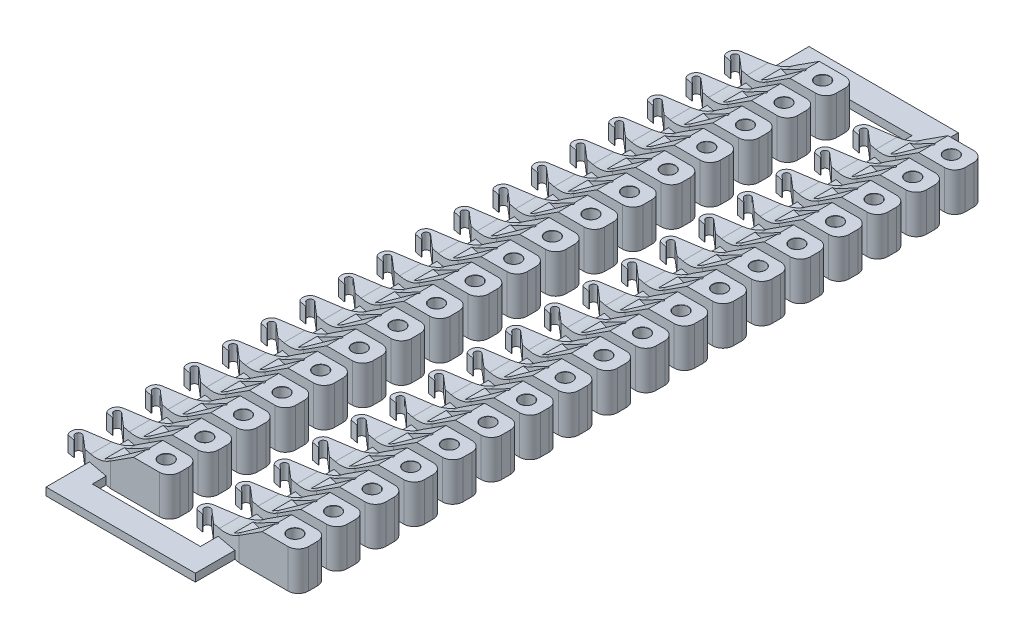
from build123d import *

# Parameters (mm, degrees)
SKETCH1_R                = 0.27
BOSS_EXTRUDE1_DEPTH      = 1.5
CUT_EXTRUDE1_DEPTH       = 1.57
CUT_EXTRUDE1_DEPTH_BACK  = 1.57
FILLET1_R                = 0.01
FILLET2_R                = 1.5
FILLET3_R                = 0.4
CUT_EXTRUDE2_DEPTH       = 0.8
FILLET4_R                = 0.05
LPATTERN2_COUNT          = 18
LPATTERN2_PITCH          = 1.5
SKETCH3_W                = 0.8
SKETCH3_H                = 0.3
BOSS_EXTRUDE2_DEPTH      = 2.0001
BOSS_EXTRUDE2_DEPTH_BACK = 27
LPATTERN4_COUNT          = 2
LPATTERN4_PITCH          = 5
SKETCH5_W                = 5.8
SKETCH5_H                = 0.9301
SKETCH5_H_2              = 0.0699
SKETCH5_H_3              = 0.43
SKETCH5_H_4              = 0.57
BOSS_EXTRUDE3_DEPTH      = 0.3


with BuildPart() as part:
    # Sketch1 → Boss-Extrude1 (new body)
    with BuildSketch(Plane(origin=(0, 0, 0), x_dir=(1, 0, 0), z_dir=(0, 1, 0))):
        with BuildLine():
            Line((0.7, -0.57), (0.7, 0.57))
            Line((0.7, 0.57), (-1.6, 0.57))
            Line((-1.6, 0.57), (-3.448849779, 0.285704322))
            ThreePointArc((-3.448849779, 0.285704322), (-3.676095639, 0.10009665), (-3.623939692, -0.188643104))
            Line((-3.623939692, -0.188643104), (-3.34104042, -0.241947849))
            Line((-3.34104042, -0.241947849), (-3.34104042, -0.220416717))
            Line((-3.34104042, -0.220416717), (-3.486679159, -0.094774919))
            ThreePointArc((-3.486679159, -0.094774919), (-3.499692238, 0.08176184), (-3.323155479, 0.094774919))
            Line((-3.323155479, 0.094774919), (-2.818770339, -0.340355572))
            Line((-2.818770339, -0.340355572), (-1.6, -0.57))
            Line((-1.6, -0.57), (0.7, -0.57))
        make_face()
        Circle(SKETCH1_R, mode=Mode.SUBTRACT)
    extrude(amount=BOSS_EXTRUDE1_DEPTH)

    # Sketch2 → Cut-Extrude1 (cut, two sides)
    with BuildSketch(Plane.XY) as cut_extrude1_sk:
        Polygon((-4.254461252, 0.6), (-2.1, 0.6), (-0.7, 1.5), (-4.254461252, 1.5), align=None)
    extrude(amount=CUT_EXTRUDE1_DEPTH, mode=Mode.SUBTRACT)
    extrude(cut_extrude1_sk.sketch, amount=-CUT_EXTRUDE1_DEPTH_BACK, mode=Mode.SUBTRACT)

    # Fillet1
    fillet1_edges = [part.edges().sort_by_distance(p)[0] for p in [
        (-0.27, 0, 0),
        (-0.27, 1.5, 0),
    ]]
    fillet(fillet1_edges, radius=FILLET1_R)

    # Fillet2
    fillet2_edges = [part.edges().sort_by_distance(p)[0] for p in [
        (-2.1, 0.6, -0.008663527),
    ]]
    fillet(fillet2_edges, radius=FILLET2_R)

    # Fillet3
    fillet3_edges = [part.edges().sort_by_distance(p)[0] for p in [
        (0.7, 0.75, -0.57),
        (0.7, 0.75, 0.57),
    ]]
    fillet(fillet3_edges, radius=FILLET3_R)

    # Sketch4 → Cut-Extrude2 (cut)
    with BuildSketch(Plane(origin=(0, 1.5, 0), x_dir=(1, 0, 0), z_dir=(0, 1, 0))):
        Polygon((-0.5, 0), (-2.5, 0.5), (-2.5, -0.5), align=None)
    extrude(amount=-CUT_EXTRUDE2_DEPTH, mode=Mode.SUBTRACT)

    # Fillet4
    fillet4_edges = [part.edges().sort_by_distance(p)[0] for p in [
        (-0.5, 1.1, 0),
    ]]
    fillet(fillet4_edges, radius=FILLET4_R)


with BuildPart() as lpattern2_1:
    # LPattern2: pattern copy
    add(part.part.moved(Location(Vector(0, 0, -1) * (1 * LPATTERN2_PITCH))))


with BuildPart() as lpattern2_2:
    # LPattern2: pattern copy
    add(part.part.moved(Location(Vector(0, 0, -1) * (2 * LPATTERN2_PITCH))))


with BuildPart() as lpattern2_3:
    # LPattern2: pattern copy
    add(part.part.moved(Location(Vector(0, 0, -1) * (3 * LPATTERN2_PITCH))))


with BuildPart() as lpattern2_4:
    # LPattern2: pattern copy
    add(part.part.moved(Location(Vector(0, 0, -1) * (4 * LPATTERN2_PITCH))))


with BuildPart() as lpattern2_5:
    # LPattern2: pattern copy
    add(part.part.moved(Location(Vector(0, 0, -1) * (5 * LPATTERN2_PITCH))))


with BuildPart() as lpattern2_6:
    # LPattern2: pattern copy
    add(part.part.moved(Location(Vector(0, 0, -1) * (6 * LPATTERN2_PITCH))))


with BuildPart() as lpattern2_7:
    # LPattern2: pattern copy
    add(part.part.moved(Location(Vector(0, 0, -1) * (7 * LPATTERN2_PITCH))))


with BuildPart() as lpattern2_8:
    # LPattern2: pattern copy
    add(part.part.moved(Location(Vector(0, 0, -1) * (8 * LPATTERN2_PITCH))))


with BuildPart() as lpattern2_9:
    # LPattern2: pattern copy
    add(part.part.moved(Location(Vector(0, 0, -1) * (9 * LPATTERN2_PITCH))))


with BuildPart() as lpattern2_10:
    # LPattern2: pattern copy
    add(part.part.moved(Location(Vector(0, 0, -1) * (10 * LPATTERN2_PITCH))))


with BuildPart() as lpattern2_11:
    # LPattern2: pattern copy
    add(part.part.moved(Location(Vector(0, 0, -1) * (11 * LPATTERN2_PITCH))))


with BuildPart() as lpattern2_12:
    # LPattern2: pattern copy
    add(part.part.moved(Location(Vector(0, 0, -1) * (12 * LPATTERN2_PITCH))))


with BuildPart() as lpattern2_13:
    # LPattern2: pattern copy
    add(part.part.moved(Location(Vector(0, 0, -1) * (13 * LPATTERN2_PITCH))))


with BuildPart() as lpattern2_14:
    # LPattern2: pattern copy
    add(part.part.moved(Location(Vector(0, 0, -1) * (14 * LPATTERN2_PITCH))))


with BuildPart() as lpattern2_15:
    # LPattern2: pattern copy
    add(part.part.moved(Location(Vector(0, 0, -1) * (15 * LPATTERN2_PITCH))))


with BuildPart() as lpattern2_16:
    # LPattern2: pattern copy
    add(part.part.moved(Location(Vector(0, 0, -1) * (16 * LPATTERN2_PITCH))))


with BuildPart() as lpattern2_17:
    # LPattern2: pattern copy
    add(part.part.moved(Location(Vector(0, 0, -1) * (17 * LPATTERN2_PITCH))))


with BuildPart() as part_1:
    add(part.part)

    add(lpattern2_1.part)  # Boss-Extrude2 merges LPattern2_1

    add(lpattern2_2.part)  # Boss-Extrude2 merges LPattern2_2

    add(lpattern2_3.part)  # Boss-Extrude2 merges LPattern2_3

    add(lpattern2_4.part)  # Boss-Extrude2 merges LPattern2_4

    add(lpattern2_5.part)  # Boss-Extrude2 merges LPattern2_5

    add(lpattern2_6.part)  # Boss-Extrude2 merges LPattern2_6

    add(lpattern2_7.part)  # Boss-Extrude2 merges LPattern2_7

    add(lpattern2_8.part)  # Boss-Extrude2 merges LPattern2_8

    add(lpattern2_9.part)  # Boss-Extrude2 merges LPattern2_9

    add(lpattern2_10.part)  # Boss-Extrude2 merges LPattern2_10

    add(lpattern2_11.part)  # Boss-Extrude2 merges LPattern2_11

    add(lpattern2_12.part)  # Boss-Extrude2 merges LPattern2_12

    add(lpattern2_13.part)  # Boss-Extrude2 merges LPattern2_13

    add(lpattern2_14.part)  # Boss-Extrude2 merges LPattern2_14

    add(lpattern2_15.part)  # Boss-Extrude2 merges LPattern2_15

    add(lpattern2_16.part)  # Boss-Extrude2 merges LPattern2_16

    add(lpattern2_17.part)  # Boss-Extrude2 merges LPattern2_17
    # Sketch3 → Boss-Extrude2 (add, two sides)
    with BuildSketch(Plane.XY) as boss_extrude2_sk:
        with Locations((-2.2, 0.15)):
            Rectangle(SKETCH3_W, SKETCH3_H)
    extrude(amount=BOSS_EXTRUDE2_DEPTH)
    extrude(boss_extrude2_sk.sketch, amount=-BOSS_EXTRUDE2_DEPTH_BACK)


with BuildPart() as lpattern4_1:
    # LPattern4: pattern copy
    add(part_1.part.moved(Location(Vector(-1, 0, 0) * (1 * LPATTERN4_PITCH))))


with BuildPart() as part_2:
    add(part_1.part)

    add(lpattern4_1.part)  # Boss-Extrude3 merges LPattern4_1
    # Sketch5 → Boss-Extrude3 (add)
    with BuildSketch(Plane(origin=(0, 0, 0), x_dir=(1, 0, 0), z_dir=(0, 1, 0))):
        with Locations((-4.7, -1.53505)):
            Rectangle(SKETCH5_W, SKETCH5_H)
        with Locations((-4.7, -2.03505)):
            Rectangle(SKETCH5_W, SKETCH5_H_2)
        with Locations((-4.7, 26.785)):
            Rectangle(SKETCH5_W, SKETCH5_H_3)
        with Locations((-4.7, 27.285)):
            Rectangle(SKETCH5_W, SKETCH5_H_4)
    extrude(amount=BOSS_EXTRUDE3_DEPTH)


solid = part_2.part
